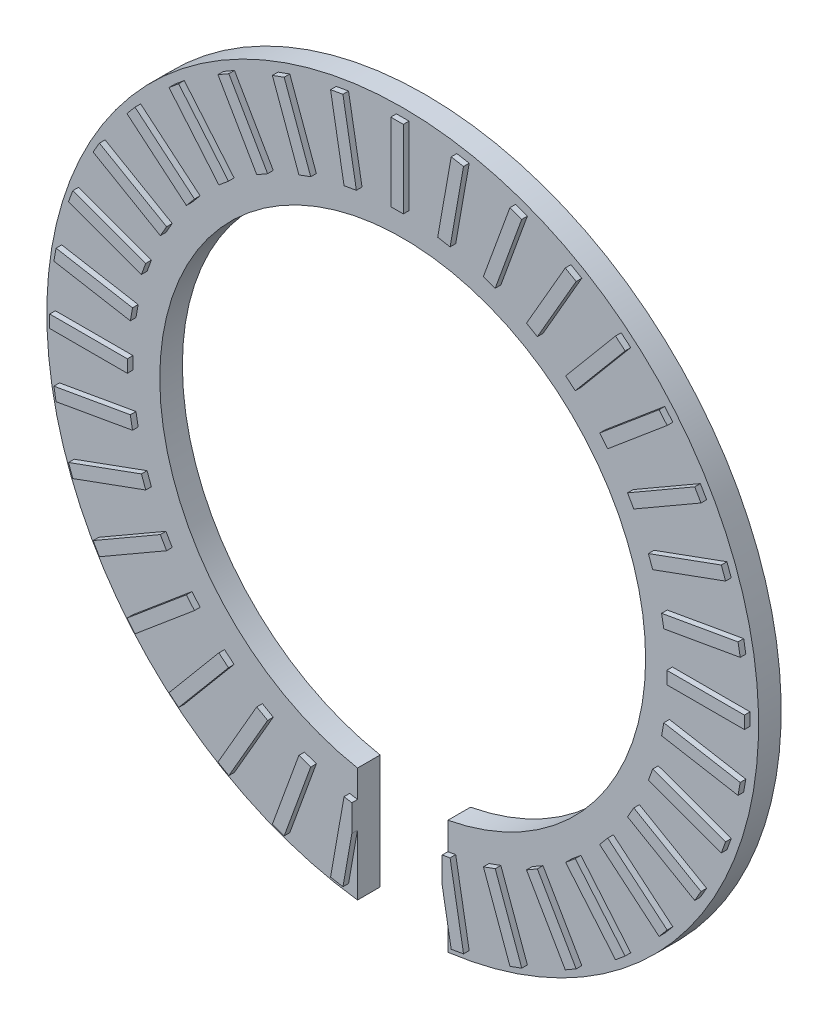
from build123d import *

# Parameters (mm, degrees)
ESQUISSE1_R                  = 31.5
ESQUISSE1_R_2                = 21.5
BOSS_EXTRU_1_DEPTH           = 2
ESQUISSE2_W                  = 1.11033496
ESQUISSE2_H                  = 6.867457902
BOSS_EXTRU_2_DEPTH           = 0.5
R_P_TITION_CIRCULAIRE1_COUNT = 36
ENL_V_MAT_EXTRU_4_DEPTH      = 1.5
ENL_V_MAT_EXTRU_4_DEPTH_BACK = 3


with BuildPart() as part:
    # Esquisse1 → Boss.-Extru.1 (new body)
    with BuildSketch(Plane.XY):
        Circle(ESQUISSE1_R)
        Circle(ESQUISSE1_R_2, mode=Mode.SUBTRACT)
    extrude(amount=BOSS_EXTRU_1_DEPTH)

    # Esquisse2 → Boss.-Extru.2 (add)
    with BuildSketch(Plane.XY.offset(2)):
        with Locations((0, 27.30701826)):
            Rectangle(ESQUISSE2_W, ESQUISSE2_H)
    boss_extru_2 = extrude(amount=BOSS_EXTRU_2_DEPTH)

    # Répétition circulaire1: Boss.-Extru.2 ×36 about axis
    r_p_tition_circulaire1_axis = Axis((0, 0, 0), (0, 0, 1))
    for i in range(1, R_P_TITION_CIRCULAIRE1_COUNT):
        add(boss_extru_2.rotate(r_p_tition_circulaire1_axis, i * 360 / R_P_TITION_CIRCULAIRE1_COUNT))

    # Esquisse3 → Enlèv. mat.-Extru.4 (cut, two sides)
    with BuildSketch(Plane.XY.offset(2)) as enl_v_mat_extru_4_sk:
        Polygon((0, 0), (-4, 0), (-4, -36.523437731), (0, -36.523437731), (4, -36.523437731), (4, 0), align=None)
    extrude(amount=ENL_V_MAT_EXTRU_4_DEPTH, mode=Mode.SUBTRACT)
    extrude(enl_v_mat_extru_4_sk.sketch, amount=-ENL_V_MAT_EXTRU_4_DEPTH_BACK, mode=Mode.SUBTRACT)


solid = part.part
